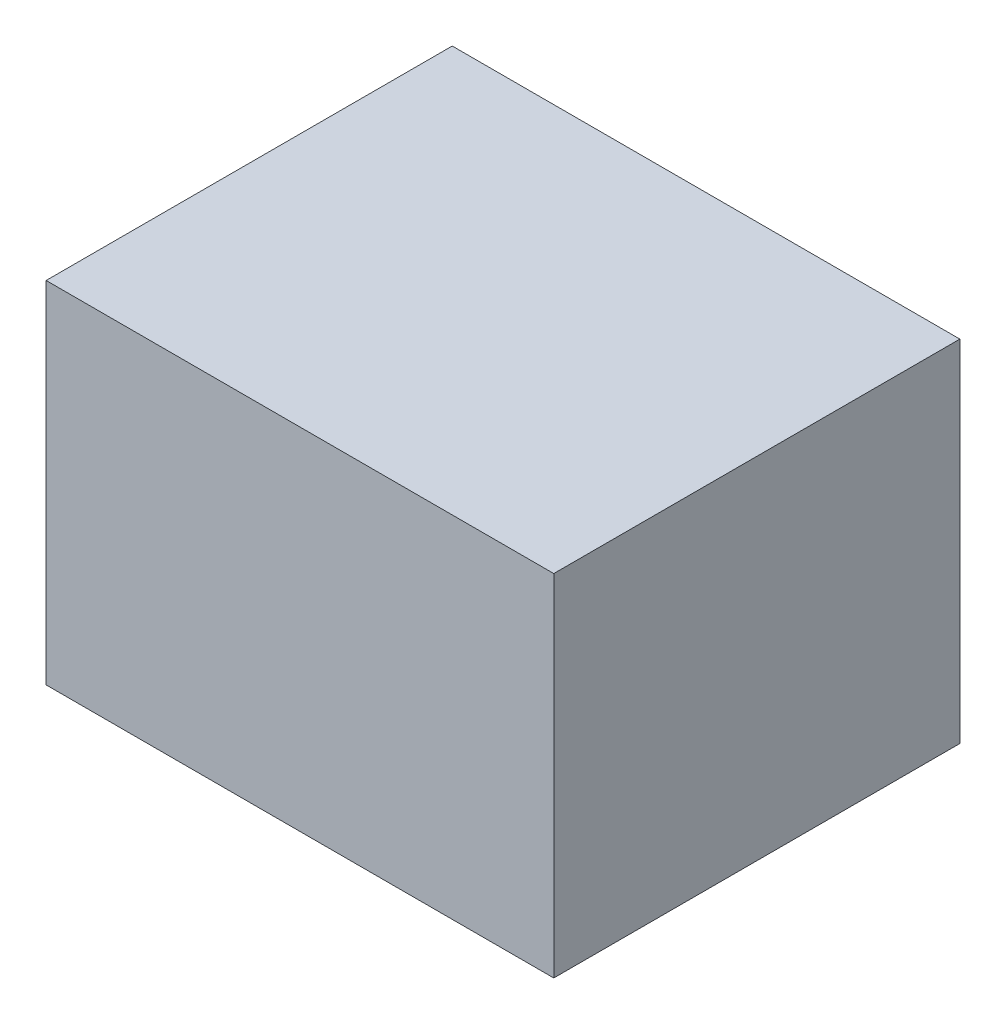
from build123d import *

# Parameters (mm, degrees)
SKETCH1_W           = 38.1
SKETCH1_H           = 30.48
BOSS_EXTRUDE1_DEPTH = 26.289


with BuildPart() as part:
    # Sketch1 → Boss-Extrude1 (new body)
    with BuildSketch(Plane(origin=(0, 0, 0), x_dir=(1, 0, 0), z_dir=(0, 1, 0))):
        with Locations((-19.05, 15.24)):
            Rectangle(SKETCH1_W, SKETCH1_H)
    extrude(amount=BOSS_EXTRUDE1_DEPTH)


solid = part.part
